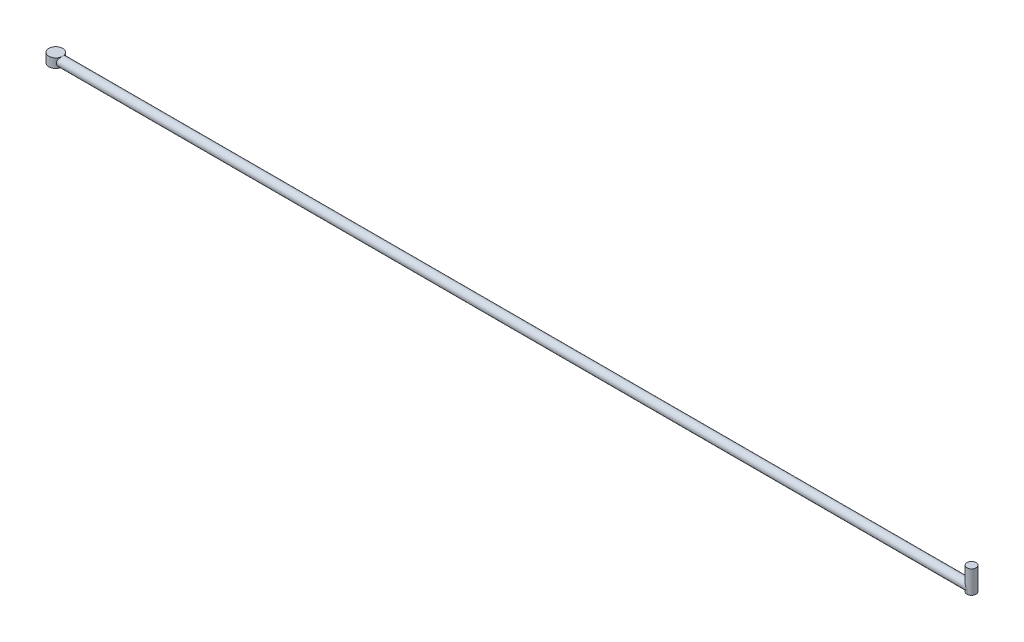
from build123d import *

# Parameters (mm, degrees)
SKETCH1_R           = 15
BOSS_EXTRUDE1_DEPTH = 20
SKETCH2_R           = 10
BOSS_EXTRUDE2_DEPTH = 2000
SKETCH3_R           = 10
BOSS_EXTRUDE3_DEPTH = 50


with BuildPart() as part:
    # Sketch1 → Boss-Extrude1 (new body)
    with BuildSketch(Plane(origin=(0, 0, 0), x_dir=(1, 0, 0), z_dir=(0, 1, 0))):
        Circle(SKETCH1_R)
    extrude(amount=BOSS_EXTRUDE1_DEPTH)

    # Sketch2 → Boss-Extrude2 (add)
    with BuildSketch(Plane(origin=(0, 0, 0), x_dir=(0, 0, -1), z_dir=(1, 0, 0))):
        with Locations((0, 10)):
            Circle(SKETCH2_R)
    extrude(amount=BOSS_EXTRUDE2_DEPTH)

    # Sketch3 → Boss-Extrude3 (add)
    with BuildSketch(Plane(origin=(0, 0, 0), x_dir=(1, 0, 0), z_dir=(0, 1, 0))):
        with Locations((2000, 0)):
            Circle(SKETCH3_R)
    extrude(amount=BOSS_EXTRUDE3_DEPTH)


solid = part.part
